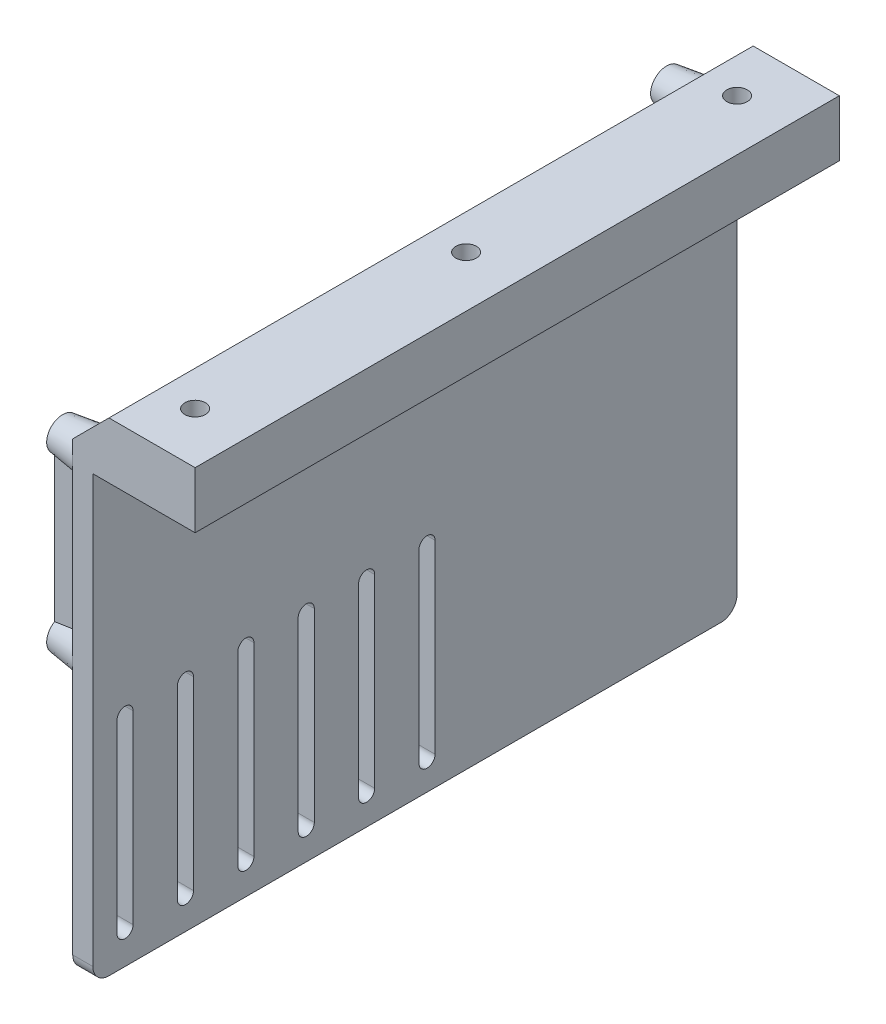
from build123d import *

# Parameters (mm, degrees)
BOSS_EXTRUDE1_DEPTH                = 80
SKETCH2_R                          = 5
SKETCH2_R_2                        = 4
BOSS_EXTRUDE2_DEPTH                = 7.5
BOSS_EXTRUDE2_TAPER                = 7.8
CUT_EXTRUDE1_DEPTH                 = 31.4
CUT_EXTRUDE2_DEPTH                 = 31.4
SKETCH6_W                          = 4
SKETCH6_H                          = 43
SKETCH6_H_2                        = 49
EXTRUDE_THIN1_DEPTH                = 7.5
TAP_DRILL_FOR_M2_5X0_45_TAP1_D     = 2.05
TAP_DRILL_FOR_M2_5X0_45_TAP1_DEPTH = 10
TAP_DRILL_FOR_M2_5X0_45_TAP1_TIP   = 0.615882135
TAP_DRILL_FOR_M3X0_5_TAP1_D        = 2.5
TAP_DRILL_FOR_M3X0_5_TAP1_DEPTH    = 10
TAP_DRILL_FOR_M3X0_5_TAP1_TIP      = 0.751075774
BOSS_EXTRUDE4_DEPTH                = 160
F_10_CLEARANCE_HOLE1_D             = 5.1054


with BuildPart() as part:
    # Sketch1 → Boss-Extrude1 (new body, symmetric)
    with BuildSketch(Plane.XY):
        Polygon((0, 5), (-30.4, 5), (-30.4, -110), (-25.4, -110), (-25.4, 0), (0, 0), align=None)
    extrude(amount=BOSS_EXTRUDE1_DEPTH, both=True)

    # Sketch2 → Boss-Extrude2 (add)
    with BuildSketch(Plane.ZY.offset(30.4)):
        with Locations((75, -43)):
            Circle(SKETCH2_R)
        with Locations((75, 0)):
            Circle(SKETCH2_R)
        with Locations((-75, 0)):
            Circle(SKETCH2_R)
        with Locations((-75, -43)):
            Circle(SKETCH2_R)
        with Locations((-76, -57)):
            Circle(SKETCH2_R_2)
        with Locations((-76, -106)):
            Circle(SKETCH2_R_2)
        with Locations((-18, -106)):
            Circle(SKETCH2_R_2)
        with Locations((-18, -57)):
            Circle(SKETCH2_R_2)
    extrude(amount=BOSS_EXTRUDE2_DEPTH, taper=BOSS_EXTRUDE2_TAPER)

    # Sketch3 → Cut-Extrude1 (cut, through all)
    with BuildSketch(Plane.ZY.offset(30.4)):
        with BuildLine():
            Line((74, -56), (74, -102))
            ThreePointArc((74, -102), (72, -104), (70, -102))
            Line((70, -102), (70, -56))
            ThreePointArc((70, -56), (72, -54), (74, -56))
        make_face()
        with BuildLine():
            Line((55, -56.167316529), (55, -102.167316529))
            ThreePointArc((55, -102.167316529), (57, -104.167316529), (59, -102.167316529))
            Line((59, -102.167316529), (59, -56.167316529))
            ThreePointArc((59, -56.167316529), (57, -54.167316529), (55, -56.167316529))
        make_face()
        with BuildLine():
            Line((40, -56.334633058), (40, -102.334633058))
            ThreePointArc((40, -102.334633058), (42, -104.334633058), (44, -102.334633058))
            Line((44, -102.334633058), (44, -56.334633058))
            ThreePointArc((44, -56.334633058), (42, -54.334633058), (40, -56.334633058))
        make_face()
        with BuildLine():
            Line((25, -56.501949587), (25, -102.501949587))
            ThreePointArc((25, -102.501949587), (27, -104.501949587), (29, -102.501949587))
            Line((29, -102.501949587), (29, -56.501949587))
            ThreePointArc((29, -56.501949587), (27, -54.501949587), (25, -56.501949587))
        make_face()
        with BuildLine():
            Line((10, -56.669266116), (10, -102.669266116))
            ThreePointArc((10, -102.669266116), (12, -104.669266116), (14, -102.669266116))
            Line((14, -102.669266116), (14, -56.669266116))
            ThreePointArc((14, -56.669266116), (12, -54.669266116), (10, -56.669266116))
        make_face()
        with BuildLine():
            Line((-5, -56.836582645), (-5, -102.836582645))
            ThreePointArc((-5, -102.836582645), (-3, -104.836582645), (-1, -102.836582645))
            Line((-1, -102.836582645), (-1, -56.836582645))
            ThreePointArc((-1, -56.836582645), (-3, -54.836582645), (-5, -56.836582645))
        make_face()
    extrude(amount=-CUT_EXTRUDE1_DEPTH, mode=Mode.SUBTRACT)

    # Sketch4 → Cut-Extrude2 (cut, through all)
    with BuildSketch(Plane.ZY.offset(30.4)):
        with BuildLine():
            ThreePointArc((80, -106), (78.828427125, -108.828427125), (76, -110))
            Line((76, -110), (80, -110))
            Line((80, -110), (80, -106))
        make_face()
        with BuildLine():
            ThreePointArc((-80, -106), (-78.828427125, -108.828427125), (-76, -110))
            Line((-76, -110), (-80, -110))
            Line((-80, -110), (-80, -106))
        make_face()
    extrude(amount=-CUT_EXTRUDE2_DEPTH, mode=Mode.SUBTRACT)

    # Sketch6 → Extrude-Thin1 (add)
    with BuildSketch(Plane.ZY.offset(37.9)):
        Polygon((-74, -106), (-74, -57.071337695), (-73, -43.071337695), (-73, 0), (-77, 0), (-77, -42.928662305), (-78, -56.928662305), (-78, -106), align=None)
        with Locations((75, -21.5)):
            Rectangle(SKETCH6_W, SKETCH6_H)
        with Locations((-18, -81.5)):
            Rectangle(SKETCH6_W, SKETCH6_H_2)
    extrude(amount=-EXTRUDE_THIN1_DEPTH)

    # Tap Drill for M2.5x0.45 Tap1
    with Locations(Plane.ZY.offset(37.9)):
        with Locations((-76, -57), (-76, -106), (-18, -106), (-18, -57)):
            Hole(TAP_DRILL_FOR_M2_5X0_45_TAP1_D / 2, depth=TAP_DRILL_FOR_M2_5X0_45_TAP1_DEPTH)
            with Locations((0, 0, -(TAP_DRILL_FOR_M2_5X0_45_TAP1_DEPTH + TAP_DRILL_FOR_M2_5X0_45_TAP1_TIP / 2))):  # 118° drill point
                Cone(0, TAP_DRILL_FOR_M2_5X0_45_TAP1_D / 2, TAP_DRILL_FOR_M2_5X0_45_TAP1_TIP, mode=Mode.SUBTRACT)

    # Tap Drill for M3x0.5 Tap1
    with Locations(Plane(origin=(-37.9, 0, -75), x_dir=(0, -1, 0), z_dir=(-1, 0, 0))):
        with Locations((0, 0), (43, 0), (43, 150), (0, 150)):
            Hole(TAP_DRILL_FOR_M3X0_5_TAP1_D / 2, depth=TAP_DRILL_FOR_M3X0_5_TAP1_DEPTH)
            with Locations((0, 0, -(TAP_DRILL_FOR_M3X0_5_TAP1_DEPTH + TAP_DRILL_FOR_M3X0_5_TAP1_TIP / 2))):  # 118° drill point
                Cone(0, TAP_DRILL_FOR_M3X0_5_TAP1_D / 2, TAP_DRILL_FOR_M3X0_5_TAP1_TIP, mode=Mode.SUBTRACT)

    # Sketch11 → Boss-Extrude4 (add)
    with BuildSketch(Plane.XY.offset(80)):
        Polygon((-30.4, 5), (-21.4, 14), (0, 14), (0, 5), align=None)
    extrude(amount=-BOSS_EXTRUDE4_DEPTH)

    # #10 Clearance Hole1 (through all)
    with Locations(Plane(origin=(0, 0, 0), x_dir=(-1, 0, 0), z_dir=(0, -1, 0))):
        with Locations((12.7, 0), (12.7, 67.3), (12.7, -67.3)):
            Hole(F_10_CLEARANCE_HOLE1_D / 2)


solid = part.part
